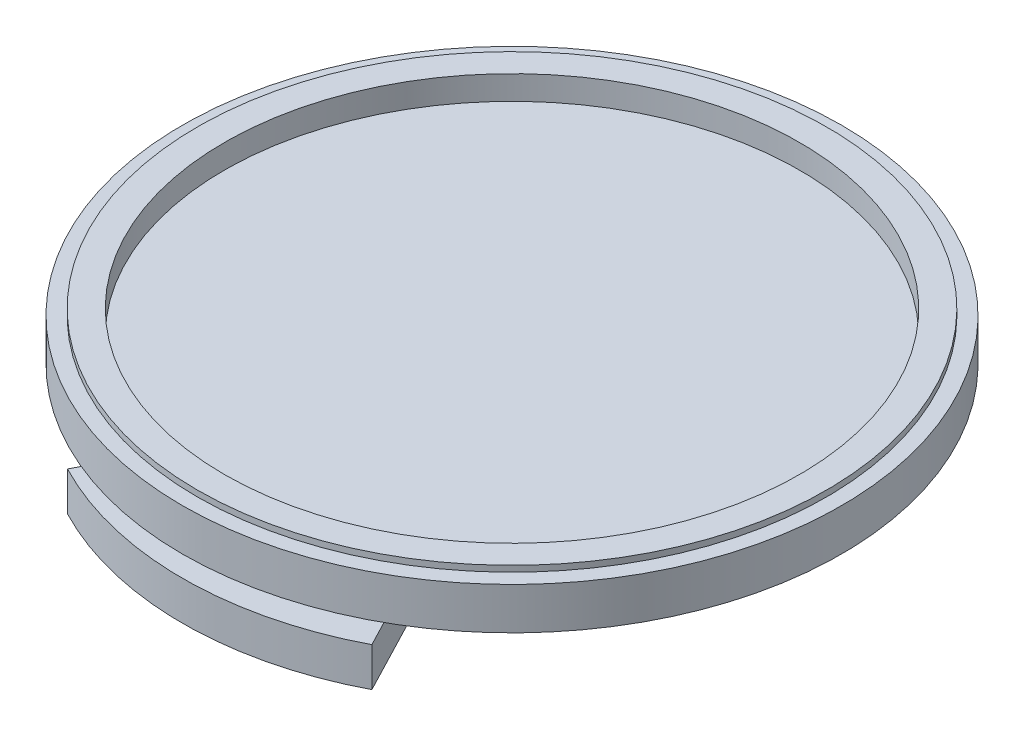
from build123d import *

# Parameters (mm, degrees)
BOSS_EXTRUDE1_DEPTH = 1.651


with BuildPart() as part:
    # Sketch1 → Revolve1 (revolve)
    with BuildSketch(Plane(origin=(0, 0, 0), x_dir=(0, 0, -1), z_dir=(1, 0, 0))):
        Polygon((0, 0), (6.6548, 0), (6.6548, 1.651), (12.5222, 1.651), (12.5222, 2.54), (13.97, 2.54), (13.97, 4.318), (13.335, 4.318), (13.335, 4.572), (12.192, 4.572), (12.192, 3.556), (0, 3.556), align=None)
    revolve(axis=Axis((0, 3.556, 0), (0, -1, 0)))

    # Sketch2 → Boss-Extrude1 (add)
    with BuildSketch(Plane.XZ.offset(-1.651)):
        with BuildLine():
            Line((-3.870376876, 7.434924804), (-6.450628127, 12.391541339))
            ThreePointArc((-6.450628127, 12.391541339), (0, 13.97), (6.450628127, 12.391541339))
            Line((6.450628127, 12.391541339), (3.870376876, 7.434924804))
            ThreePointArc((3.870376876, 7.434924804), (0, 8.382), (-3.870376876, 7.434924804))
        make_face()
    extrude(amount=BOSS_EXTRUDE1_DEPTH)


solid = part.part
